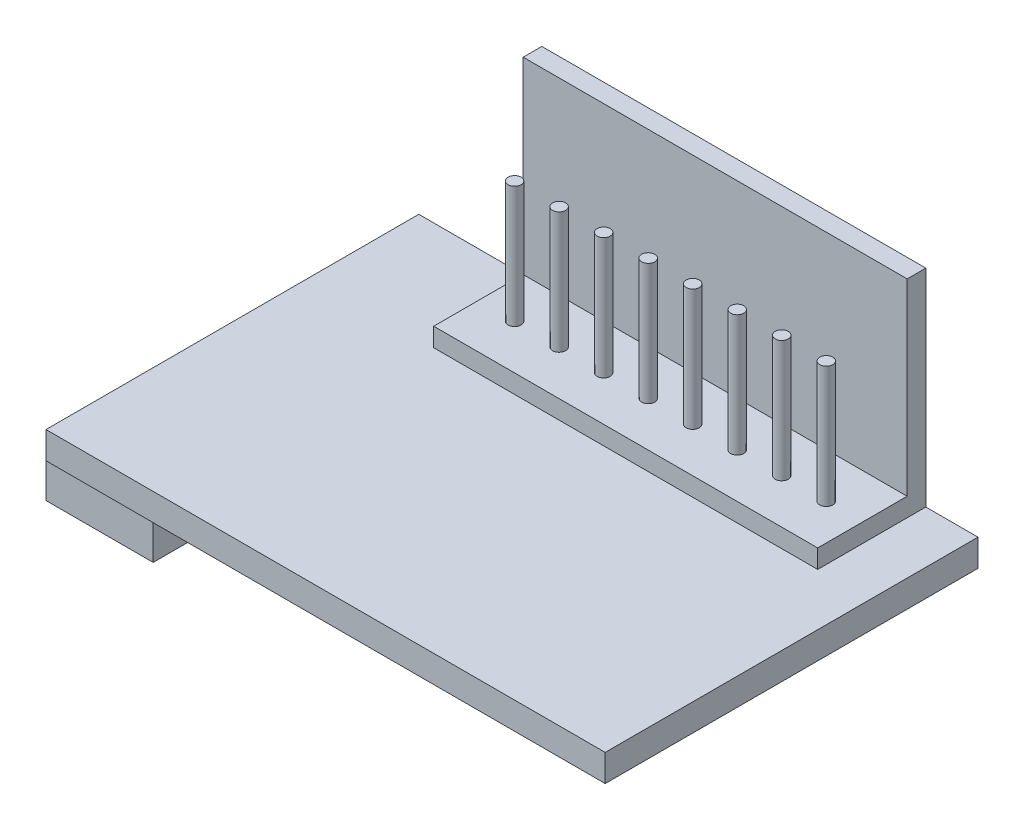
from build123d import *

# Parameters (mm, degrees)
SKETCH1_W             = 30
SKETCH1_H             = 20
BOSS_EXTRUDE1_DEPTH   = 1.45
SKETCH2_W             = 20.6
SKETCH2_H             = 5.8
BOSS_EXTRUDE2_DEPTH   = 11.1
SKETCH4_W             = 5.75
SKETCH4_H             = 15.5
BOSS_EXTRUDE3_DEPTH   = 2.85
SKETCH5_W             = 20.6
SKETCH5_H             = 10.1
CUT_EXTRUDE1_DEPTH    = 4.8
SKETCH6_R             = 0.35
BOSS_EXTRUDE4_DEPTH   = 6.52
BOSS_EXTRUDE4_2_DEPTH = 6.52
BOSS_EXTRUDE4_3_DEPTH = 6.52
BOSS_EXTRUDE4_4_DEPTH = 6.52
BOSS_EXTRUDE4_5_DEPTH = 6.52
BOSS_EXTRUDE4_6_DEPTH = 6.52
BOSS_EXTRUDE4_7_DEPTH = 6.52
BOSS_EXTRUDE4_8_DEPTH = 6.52


with BuildPart() as part:
    # Sketch1 → Boss-Extrude1 (new body)
    with BuildSketch(Plane(origin=(0, 0, 0), x_dir=(1, 0, 0), z_dir=(0, 1, 0))):
        with Locations((15, 10)):
            Rectangle(SKETCH1_W, SKETCH1_H)
    extrude(amount=BOSS_EXTRUDE1_DEPTH)


with BuildPart() as body_2:
    # Sketch2 → Boss-Extrude2 (new body)
    with BuildSketch(Plane(origin=(0, 1.45, 0), x_dir=(1, 0, 0), z_dir=(0, 1, 0))):
        with Locations((16.9, 17.1)):
            Rectangle(SKETCH2_W, SKETCH2_H)
    extrude(amount=BOSS_EXTRUDE2_DEPTH)

    # Sketch5 → Cut-Extrude1 (cut)
    with BuildSketch(Plane.XY.offset(-14.2)):
        with Locations((16.9, 7.5)):
            Rectangle(SKETCH5_W, SKETCH5_H)
    extrude(amount=-CUT_EXTRUDE1_DEPTH, mode=Mode.SUBTRACT)


with BuildPart() as body_3:
    # Sketch4 → Boss-Extrude3 (new body)
    with BuildSketch(Plane.XZ):
        with Locations((1.875, -8.75)):
            Rectangle(SKETCH4_W, SKETCH4_H)
    extrude(amount=BOSS_EXTRUDE3_DEPTH)


with BuildPart() as body_4:
    # Sketch6 → Boss-Extrude4 (new body)
    with BuildSketch(Plane(origin=(0, 2.45, 0), x_dir=(1, 0, 0), z_dir=(0, 1, 0))):
        with Locations((8.539449329, 16.6)):
            Circle(SKETCH6_R)
    extrude(amount=BOSS_EXTRUDE4_DEPTH)


with BuildPart() as body_5:
    # Sketch6 → Boss-Extrude4 2 (new body)
    with BuildSketch(Plane(origin=(0, 2.45, 0), x_dir=(1, 0, 0), z_dir=(0, 1, 0))):
        with Locations((10.928178092, 16.6)):
            Circle(SKETCH6_R)
    extrude(amount=BOSS_EXTRUDE4_2_DEPTH)


with BuildPart() as body_6:
    # Sketch6 → Boss-Extrude4 3 (new body)
    with BuildSketch(Plane(origin=(0, 2.45, 0), x_dir=(1, 0, 0), z_dir=(0, 1, 0))):
        with Locations((13.316906855, 16.6)):
            Circle(SKETCH6_R)
    extrude(amount=BOSS_EXTRUDE4_3_DEPTH)


with BuildPart() as body_7:
    # Sketch6 → Boss-Extrude4 4 (new body)
    with BuildSketch(Plane(origin=(0, 2.45, 0), x_dir=(1, 0, 0), z_dir=(0, 1, 0))):
        with Locations((15.705635618, 16.6)):
            Circle(SKETCH6_R)
    extrude(amount=BOSS_EXTRUDE4_4_DEPTH)


with BuildPart() as body_8:
    # Sketch6 → Boss-Extrude4 5 (new body)
    with BuildSketch(Plane(origin=(0, 2.45, 0), x_dir=(1, 0, 0), z_dir=(0, 1, 0))):
        with Locations((18.094364382, 16.6)):
            Circle(SKETCH6_R)
    extrude(amount=BOSS_EXTRUDE4_5_DEPTH)


with BuildPart() as body_9:
    # Sketch6 → Boss-Extrude4 6 (new body)
    with BuildSketch(Plane(origin=(0, 2.45, 0), x_dir=(1, 0, 0), z_dir=(0, 1, 0))):
        with Locations((20.483093145, 16.6)):
            Circle(SKETCH6_R)
    extrude(amount=BOSS_EXTRUDE4_6_DEPTH)


with BuildPart() as body_10:
    # Sketch6 → Boss-Extrude4 7 (new body)
    with BuildSketch(Plane(origin=(0, 2.45, 0), x_dir=(1, 0, 0), z_dir=(0, 1, 0))):
        with Locations((22.871821908, 16.6)):
            Circle(SKETCH6_R)
    extrude(amount=BOSS_EXTRUDE4_7_DEPTH)


with BuildPart() as body_11:
    # Sketch6 → Boss-Extrude4 8 (new body)
    with BuildSketch(Plane(origin=(0, 2.45, 0), x_dir=(1, 0, 0), z_dir=(0, 1, 0))):
        with Locations((25.260550671, 16.6)):
            Circle(SKETCH6_R)
    extrude(amount=BOSS_EXTRUDE4_8_DEPTH)


solid = Compound([part.part, body_2.part, body_3.part, body_4.part, body_5.part, body_6.part, body_7.part, body_8.part, body_9.part, body_10.part, body_11.part])
